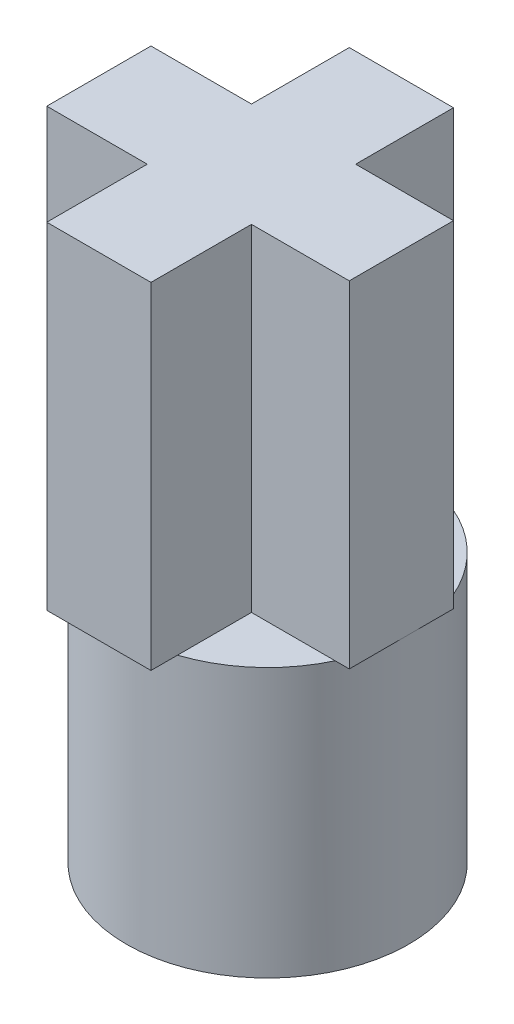
from build123d import *

# Parameters (mm, degrees)
SKETCH1_R           = 2.1
BOSS_EXTRUDE1_DEPTH = 4
SKETCH2_R           = 1.6
CUT_EXTRUDE1_DEPTH  = 3
BOSS_EXTRUDE2_DEPTH = 5


with BuildPart() as part:
    # Sketch1 → Boss-Extrude1 (new body)
    with BuildSketch(Plane(origin=(0, 0, 0), x_dir=(1, 0, 0), z_dir=(0, 1, 0))):
        Circle(SKETCH1_R)
    extrude(amount=BOSS_EXTRUDE1_DEPTH)

    # Sketch2 → Cut-Extrude1 (cut)
    with BuildSketch(Plane(origin=(0, 0, 0), x_dir=(-1, 0, 0), z_dir=(0, -1, 0))):
        Circle(SKETCH2_R)
    extrude(amount=-CUT_EXTRUDE1_DEPTH, mode=Mode.SUBTRACT)

    # Sketch3 → Boss-Extrude2 (add)
    with BuildSketch(Plane(origin=(0, 4, 0), x_dir=(1, 0, 0), z_dir=(0, 1, 0))):
        Polygon((-0.895, 0.655), (-2.39, 0.655), (-2.39, -0.895), (-0.895, -0.895), (-0.895, -2.39), (0.655, -2.39), (0.655, -0.895), (2.11, -0.895), (2.11, 0.655), (0.655, 0.655), (0.655, 2.11), (-0.895, 2.11), align=None)
    extrude(amount=BOSS_EXTRUDE2_DEPTH)


solid = part.part
